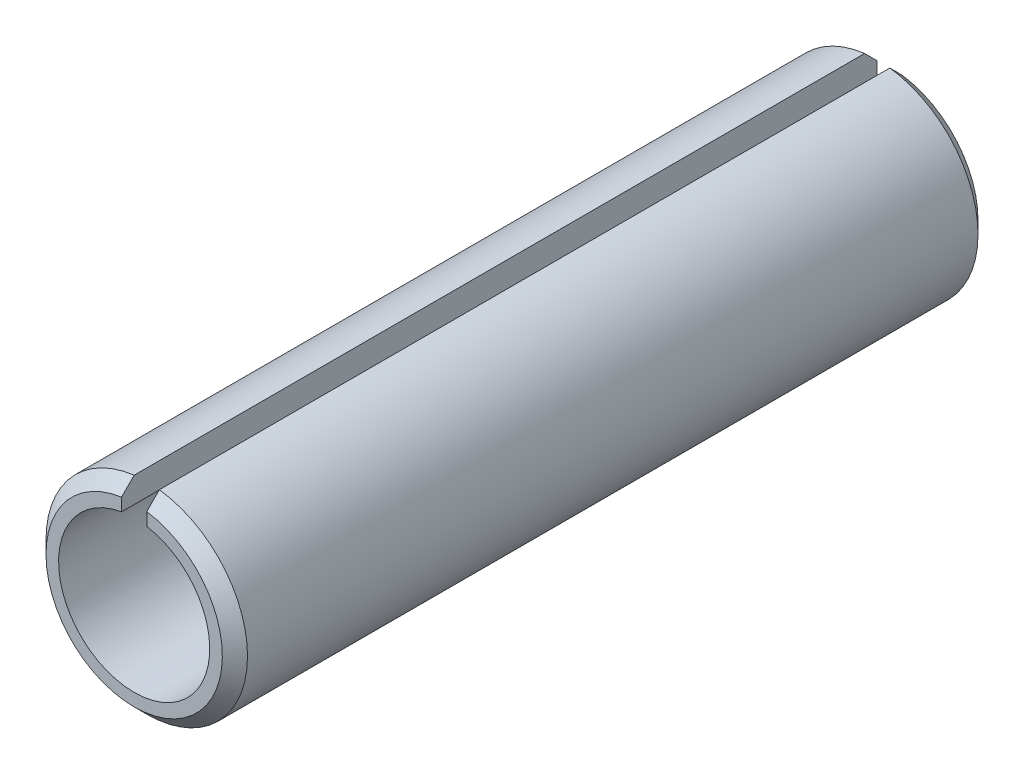
from build123d import *

# Parameters (mm, degrees)
EXTRUSION1_DEPTH      = 15
EXTRUSION1_DEPTH_BACK = 15
CHANFREIN1_SIZE       = 0.5


with BuildPart() as part:
    # Esquisse1 → Extrusion1 (new body, two sides)
    with BuildSketch(Plane.XY) as extrusion1_sk:
        with BuildLine():
            Line((0.5, 3.968626967), (0.5, 2.958039892))
            ThreePointArc((0.5, 2.958039892), (0, -3), (-0.5, 2.958039892))
            Line((-0.5, 2.958039892), (-0.5, 3.968626967))
            ThreePointArc((-0.5, 3.968626967), (0, -4), (0.5, 3.968626967))
        make_face()
    extrude(amount=EXTRUSION1_DEPTH)
    extrude(extrusion1_sk.sketch, amount=-EXTRUSION1_DEPTH_BACK)

    # Chanfrein1
    chanfrein1_edges = [part.edges().sort_by_distance(p)[0] for p in [
        (0, -4, -15),
        (0, -4, 15),
    ]]
    chamfer(chanfrein1_edges, length=CHANFREIN1_SIZE)


solid = part.part
